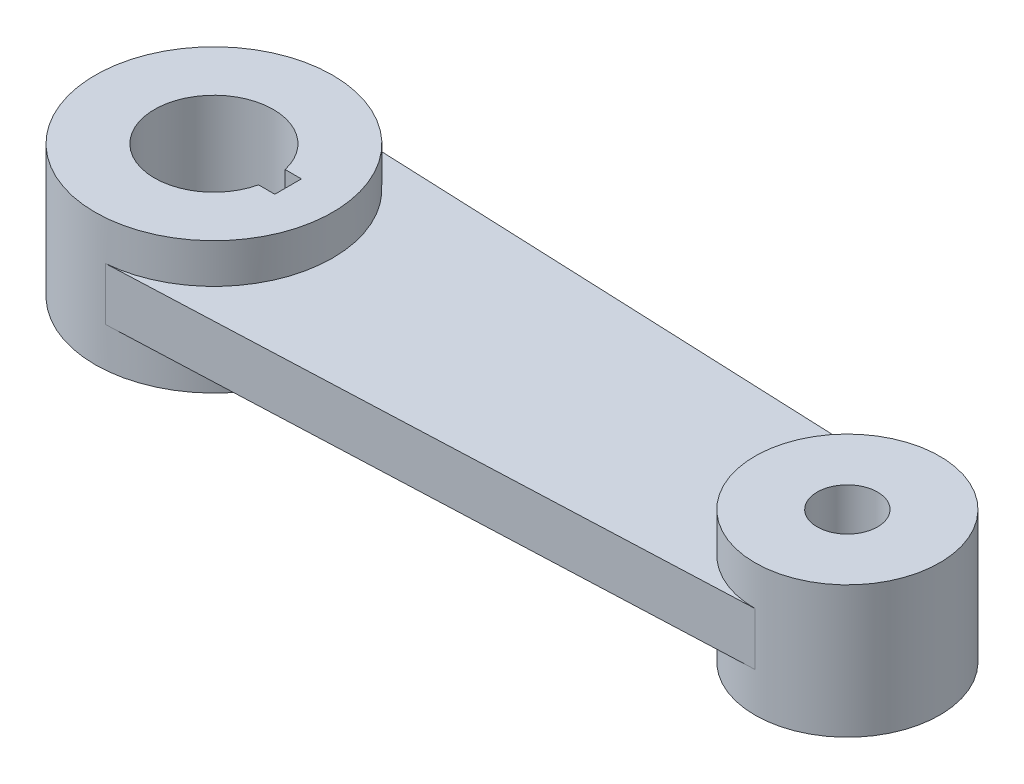
from build123d import *

# Parameters (mm, degrees)
SKETCH1_R                = 21.9
BOSS_EXTRUDE3_DEPTH      = 12.5
SKETCH2_R                = 43.75
SKETCH2_R_2              = 56.25
BOSS_EXTRUDE4_DEPTH      = 18.75
BOSS_EXTRUDE4_DEPTH_BACK = 43.75
SKETCH3_R                = 14.300981298
CUT_EXTRUDE1_DEPTH       = 223.731621015


with BuildPart() as part:
    # Sketch1 → Boss-Extrude3 (new, symmetric)
    with BuildSketch(Plane(origin=(0, 0, 0), x_dir=(1, 0, 0), z_dir=(0, 1, 0))):
        with BuildLine():
            Line((-145.320623917, 56.055025997), (-150, 56.25))
            ThreePointArc((-150, 56.25), (-206.25, 0), (-150, -56.25))
            Line((-150, -56.25), (-145.320623917, -56.055025997))
            Line((-145.320623917, -56.055025997), (150, -43.75))
            ThreePointArc((150, -43.75), (193.75, 0), (150, 43.75))
            Line((150, 43.75), (-145.320623917, 56.055025997))
        make_face()
        with BuildLine():
            Line((-122.564029086, 6.3), (-114.864029086, 6.3))
            Line((-114.864029086, 6.3), (-114.864029086, -6.3))
            Line((-114.864029086, -6.3), (-122.564029086, -6.3))
            ThreePointArc((-122.564029086, -6.3), (-178.15, 0), (-122.564029086, 6.3))
        make_face(mode=Mode.SUBTRACT)
        with Locations(Location((150, 0, 0), (0, 0, 270))):
            Circle(SKETCH1_R, mode=Mode.SUBTRACT)
    extrude(amount=BOSS_EXTRUDE3_DEPTH, both=True)

    # Sketch2 → Boss-Extrude4 (add, two sides)
    with BuildSketch(Plane(origin=(0, 12.5, 0), x_dir=(1, 0, 0), z_dir=(0, 1, 0))) as boss_extrude4_sk:
        with Locations(Location((150, 0, 0), (0, 0, 270))):
            Circle(SKETCH2_R)
        with Locations(Location((-150, 0, 0), (0, 0, 270))):
            Circle(SKETCH2_R_2)
    extrude(amount=BOSS_EXTRUDE4_DEPTH)
    extrude(boss_extrude4_sk.sketch, amount=-BOSS_EXTRUDE4_DEPTH_BACK)

    # Sketch3 → Cut-Extrude1 (cut, through all)
    with BuildSketch(Plane(origin=(0, 31.25, 0), x_dir=(1, 0, 0), z_dir=(0, 1, 0))):
        with Locations(Location((150, 0, 0), (0, 0, 270))):
            Circle(SKETCH3_R)
        with BuildLine():
            Line((-114.864029086, -6.3), (-114.864029086, 6.3))
            Line((-114.864029086, 6.3), (-122.564029086, 6.3))
            ThreePointArc((-122.564029086, 6.3), (-178.15, 0), (-122.564029086, -6.3))
            Line((-122.564029086, -6.3), (-114.864029086, -6.3))
        make_face()
    extrude(amount=-CUT_EXTRUDE1_DEPTH, mode=Mode.SUBTRACT)


solid = part.part
